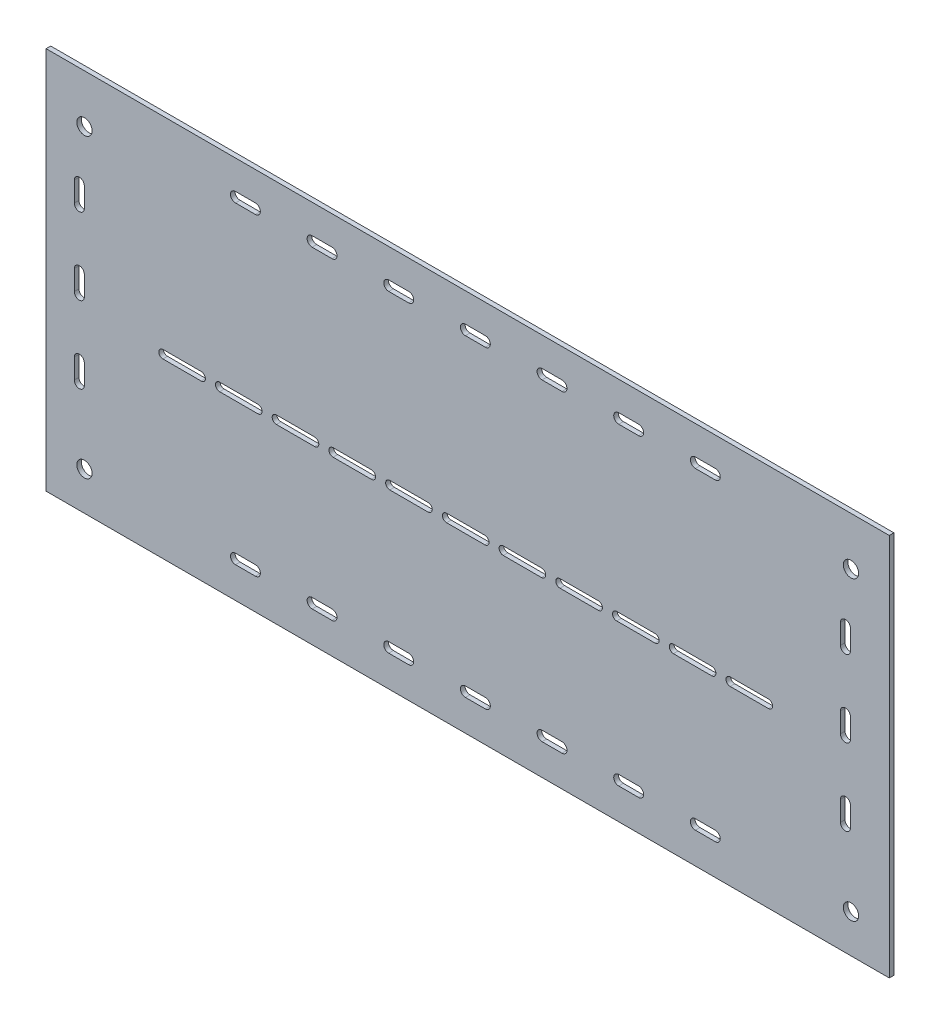
from build123d import *

# Parameters (mm, degrees)
CROQUIS1_W              = 550
CROQUIS1_H              = 250
SALIENTE_EXTRUIR1_DEPTH = 3
CROQUIS2_R              = 5
CORTAR_EXTRUIR1_DEPTH   = 4
CORTAR_EXTRUIR2_DEPTH   = 4


with BuildPart() as part:
    # Croquis1 → Saliente-Extruir1 (new body)
    with BuildSketch(Plane.XY):
        Rectangle(CROQUIS1_W, CROQUIS1_H)
    extrude(amount=SALIENTE_EXTRUIR1_DEPTH)

    # Croquis2 → Cortar-Extruir1 (cut, through all)
    with BuildSketch(Plane(origin=(0, 0, 0), x_dir=(-1, 0, 0), z_dir=(0, 0, -1))):
        with Locations((-250, -100)):
            Circle(CROQUIS2_R)
        with Locations((250, -100)):
            Circle(CROQUIS2_R)
        with Locations((250, 93.5)):
            Circle(CROQUIS2_R)
        with Locations((-250, 93.5)):
            Circle(CROQUIS2_R)
    extrude(amount=-CORTAR_EXTRUIR1_DEPTH, mode=Mode.SUBTRACT)

    # Croquis3 → Cortar-Extruir2 (cut, through all)
    with BuildSketch(Plane.XY.offset(3)):
        with BuildLine():
            Line((171.181949448, -12.194513293), (196.181949448, -12.194513293))
            ThreePointArc((196.181949448, -12.194513293), (198.091137757, -11.403701602), (198.881949448, -9.494513293))
            ThreePointArc((198.881949448, -9.494513293), (198.091137757, -7.585324983), (196.181949448, -6.794513293))
            Line((196.181949448, -6.794513293), (171.181949448, -6.794513293))
            ThreePointArc((171.181949448, -6.794513293), (168.481949448, -9.494513293), (171.181949448, -12.194513293))
        make_face()
        with BuildLine():
            Line((97.181949448, -12.194513293), (122.181949448, -12.194513293))
            ThreePointArc((122.181949448, -12.194513293), (124.091137757, -11.403701602), (124.881949448, -9.494513293))
            ThreePointArc((124.881949448, -9.494513293), (124.091137757, -7.585324983), (122.181949448, -6.794513293))
            Line((122.181949448, -6.794513293), (97.181949448, -6.794513293))
            ThreePointArc((97.181949448, -6.794513293), (94.481949448, -9.494513293), (97.181949448, -12.194513293))
        make_face()
        with BuildLine():
            Line((159.181949448, -6.794513293), (134.181949448, -6.794513293))
            ThreePointArc((134.181949448, -6.794513293), (131.481949448, -9.494513293), (134.181949448, -12.194513293))
            Line((134.181949448, -12.194513293), (159.181949448, -12.194513293))
            ThreePointArc((159.181949448, -12.194513293), (161.091137757, -11.403701602), (161.881949448, -9.494513293))
            ThreePointArc((161.881949448, -9.494513293), (161.091137757, -7.585324983), (159.181949448, -6.794513293))
        make_face()
        with BuildLine():
            Line((23.181949448, -12.194513293), (48.181949448, -12.194513293))
            ThreePointArc((48.181949448, -12.194513293), (50.091137757, -11.403701602), (50.881949448, -9.494513293))
            ThreePointArc((50.881949448, -9.494513293), (50.091137757, -7.585324983), (48.181949448, -6.794513293))
            Line((48.181949448, -6.794513293), (23.181949448, -6.794513293))
            ThreePointArc((23.181949448, -6.794513293), (20.481949448, -9.494513293), (23.181949448, -12.194513293))
        make_face()
        with BuildLine():
            Line((85.181949448, -6.794513293), (60.181949448, -6.794513293))
            ThreePointArc((60.181949448, -6.794513293), (57.481949448, -9.494513293), (60.181949448, -12.194513293))
            Line((60.181949448, -12.194513293), (85.181949448, -12.194513293))
            ThreePointArc((85.181949448, -12.194513293), (87.091137757, -11.403701602), (87.881949448, -9.494513293))
            ThreePointArc((87.881949448, -9.494513293), (87.091137757, -7.585324983), (85.181949448, -6.794513293))
        make_face()
        with BuildLine():
            Line((-101.5, 99.605015398), (-88.5, 99.605015398))
            ThreePointArc((-88.5, 99.605015398), (-86.201902961, 100.556918359), (-85.25, 102.855015398))
            ThreePointArc((-85.25, 102.855015398), (-86.201902961, 105.153112437), (-88.5, 106.105015398))
            Line((-88.5, 106.105015398), (-101.5, 106.105015398))
            ThreePointArc((-101.5, 106.105015398), (-104.75, 102.855015398), (-101.5, 99.605015398))
        make_face()
        with BuildLine():
            Line((-138.5, 106.105015398), (-151.5, 106.105015398))
            ThreePointArc((-151.5, 106.105015398), (-154.75, 102.855015398), (-151.5, 99.605015398))
            Line((-151.5, 99.605015398), (-138.5, 99.605015398))
            ThreePointArc((-138.5, 99.605015398), (-136.201902961, 100.556918359), (-135.25, 102.855015398))
            ThreePointArc((-135.25, 102.855015398), (-136.201902961, 105.153112437), (-138.5, 106.105015398))
        make_face()
        with BuildLine():
            Line((-1.5, 99.605015398), (11.5, 99.605015398))
            ThreePointArc((11.5, 99.605015398), (13.798097039, 100.556918359), (14.75, 102.855015398))
            ThreePointArc((14.75, 102.855015398), (13.798097039, 105.153112437), (11.5, 106.105015398))
            Line((11.5, 106.105015398), (-1.5, 106.105015398))
            ThreePointArc((-1.5, 106.105015398), (-4.75, 102.855015398), (-1.5, 99.605015398))
        make_face()
        with BuildLine():
            Line((-38.5, 106.105015398), (-51.5, 106.105015398))
            ThreePointArc((-51.5, 106.105015398), (-54.75, 102.855015398), (-51.5, 99.605015398))
            Line((-51.5, 99.605015398), (-38.5, 99.605015398))
            ThreePointArc((-38.5, 99.605015398), (-36.201902961, 100.556918359), (-35.25, 102.855015398))
            ThreePointArc((-35.25, 102.855015398), (-36.201902961, 105.153112437), (-38.5, 106.105015398))
        make_face()
        with BuildLine():
            Line((98.5, 99.605015398), (111.5, 99.605015398))
            ThreePointArc((111.5, 99.605015398), (113.798097039, 100.556918359), (114.75, 102.855015398))
            ThreePointArc((114.75, 102.855015398), (113.798097039, 105.153112437), (111.5, 106.105015398))
            Line((111.5, 106.105015398), (98.5, 106.105015398))
            ThreePointArc((98.5, 106.105015398), (95.25, 102.855015398), (98.5, 99.605015398))
        make_face()
        with BuildLine():
            Line((61.5, 106.105015398), (48.5, 106.105015398))
            ThreePointArc((48.5, 106.105015398), (45.25, 102.855015398), (48.5, 99.605015398))
            Line((48.5, 99.605015398), (61.5, 99.605015398))
            ThreePointArc((61.5, 99.605015398), (63.798097039, 100.556918359), (64.75, 102.855015398))
            ThreePointArc((64.75, 102.855015398), (63.798097039, 105.153112437), (61.5, 106.105015398))
        make_face()
        with BuildLine():
            Line((249.649280183, 47), (249.649280183, 60))
            ThreePointArc((249.649280183, 60), (246.399280183, 63.25), (243.149280183, 60))
            Line((243.149280183, 60), (243.149280183, 47))
            ThreePointArc((243.149280183, 47), (246.399280183, 43.75), (249.649280183, 47))
        make_face()
        with BuildLine():
            Line((161.5, 106.105015398), (148.5, 106.105015398))
            ThreePointArc((148.5, 106.105015398), (145.25, 102.855015398), (148.5, 99.605015398))
            Line((148.5, 99.605015398), (161.5, 99.605015398))
            ThreePointArc((161.5, 99.605015398), (163.798097039, 100.556918359), (164.75, 102.855015398))
            ThreePointArc((164.75, 102.855015398), (163.798097039, 105.153112437), (161.5, 106.105015398))
        make_face()
        with BuildLine():
            Line((243.149280183, -40), (243.149280183, -53))
            ThreePointArc((243.149280183, -53), (246.399280183, -56.25), (249.649280183, -53))
            Line((249.649280183, -53), (249.649280183, -40))
            ThreePointArc((249.649280183, -40), (246.399280183, -36.75), (243.149280183, -40))
        make_face()
        with BuildLine():
            Line((243.149280183, 10), (243.149280183, -3))
            ThreePointArc((243.149280183, -3), (246.399280183, -6.25), (249.649280183, -3))
            Line((249.649280183, -3), (249.649280183, 10))
            ThreePointArc((249.649280183, 10), (246.399280183, 13.25), (243.149280183, 10))
        make_face()
        with BuildLine():
            Line((98.5, -104.75), (111.5, -104.75))
            ThreePointArc((111.5, -104.75), (113.798097039, -103.798097039), (114.75, -101.5))
            ThreePointArc((114.75, -101.5), (113.798097039, -99.201902961), (111.5, -98.25))
            Line((111.5, -98.25), (98.5, -98.25))
            ThreePointArc((98.5, -98.25), (95.25, -101.5), (98.5, -104.75))
        make_face()
        with BuildLine():
            Line((161.5, -98.25), (148.5, -98.25))
            ThreePointArc((148.5, -98.25), (145.25, -101.5), (148.5, -104.75))
            Line((148.5, -104.75), (161.5, -104.75))
            ThreePointArc((161.5, -104.75), (163.798097039, -103.798097039), (164.75, -101.5))
            ThreePointArc((164.75, -101.5), (163.798097039, -99.201902961), (161.5, -98.25))
        make_face()
        with BuildLine():
            Line((-1.5, -104.75), (11.5, -104.75))
            ThreePointArc((11.5, -104.75), (13.798097039, -103.798097039), (14.75, -101.5))
            ThreePointArc((14.75, -101.5), (13.798097039, -99.201902961), (11.5, -98.25))
            Line((11.5, -98.25), (-1.5, -98.25))
            ThreePointArc((-1.5, -98.25), (-4.75, -101.5), (-1.5, -104.75))
        make_face()
        with BuildLine():
            Line((61.5, -98.25), (48.5, -98.25))
            ThreePointArc((48.5, -98.25), (45.25, -101.5), (48.5, -104.75))
            Line((48.5, -104.75), (61.5, -104.75))
            ThreePointArc((61.5, -104.75), (63.798097039, -103.798097039), (64.75, -101.5))
            ThreePointArc((64.75, -101.5), (63.798097039, -99.201902961), (61.5, -98.25))
        make_face()
        with BuildLine():
            Line((-50.818050552, -12.194513293), (-25.818050552, -12.194513293))
            ThreePointArc((-25.818050552, -12.194513293), (-23.908862243, -11.403701602), (-23.118050552, -9.494513293))
            ThreePointArc((-23.118050552, -9.494513293), (-23.908862243, -7.585324983), (-25.818050552, -6.794513293))
            Line((-25.818050552, -6.794513293), (-50.818050552, -6.794513293))
            ThreePointArc((-50.818050552, -6.794513293), (-53.518050552, -9.494513293), (-50.818050552, -12.194513293))
        make_face()
        with BuildLine():
            Line((11.181949448, -6.794513293), (-13.818050552, -6.794513293))
            ThreePointArc((-13.818050552, -6.794513293), (-16.518050552, -9.494513293), (-13.818050552, -12.194513293))
            Line((-13.818050552, -12.194513293), (11.181949448, -12.194513293))
            ThreePointArc((11.181949448, -12.194513293), (13.091137757, -11.403701602), (13.881949448, -9.494513293))
            ThreePointArc((13.881949448, -9.494513293), (13.091137757, -7.585324983), (11.181949448, -6.794513293))
        make_face()
        with BuildLine():
            Line((-99.818050552, -6.794513293), (-124.818050552, -6.794513293))
            ThreePointArc((-124.818050552, -6.794513293), (-127.518050552, -9.494513293), (-124.818050552, -12.194513293))
            Line((-124.818050552, -12.194513293), (-99.818050552, -12.194513293))
            ThreePointArc((-99.818050552, -12.194513293), (-97.908862243, -11.403701602), (-97.118050552, -9.494513293))
            ThreePointArc((-97.118050552, -9.494513293), (-97.908862243, -7.585324983), (-99.818050552, -6.794513293))
        make_face()
        with BuildLine():
            Line((-62.818050552, -6.794513293), (-87.818050552, -6.794513293))
            ThreePointArc((-87.818050552, -6.794513293), (-90.518050552, -9.494513293), (-87.818050552, -12.194513293))
            Line((-87.818050552, -12.194513293), (-62.818050552, -12.194513293))
            ThreePointArc((-62.818050552, -12.194513293), (-60.908862243, -11.403701602), (-60.118050552, -9.494513293))
            ThreePointArc((-60.118050552, -9.494513293), (-60.908862243, -7.585324983), (-62.818050552, -6.794513293))
        make_face()
        with BuildLine():
            Line((-173.818050552, -6.794513293), (-198.818050552, -6.794513293))
            ThreePointArc((-198.818050552, -6.794513293), (-201.518050552, -9.494513293), (-198.818050552, -12.194513293))
            Line((-198.818050552, -12.194513293), (-173.818050552, -12.194513293))
            ThreePointArc((-173.818050552, -12.194513293), (-171.908862243, -11.403701602), (-171.118050552, -9.494513293))
            ThreePointArc((-171.118050552, -9.494513293), (-171.908862243, -7.585324983), (-173.818050552, -6.794513293))
        make_face()
        with BuildLine():
            Line((-136.818050552, -6.794513293), (-161.818050552, -6.794513293))
            ThreePointArc((-161.818050552, -6.794513293), (-164.518050552, -9.494513293), (-161.818050552, -12.194513293))
            Line((-161.818050552, -12.194513293), (-136.818050552, -12.194513293))
            ThreePointArc((-136.818050552, -12.194513293), (-134.908862243, -11.403701602), (-134.118050552, -9.494513293))
            ThreePointArc((-134.118050552, -9.494513293), (-134.908862243, -7.585324983), (-136.818050552, -6.794513293))
        make_face()
        with BuildLine():
            Line((-101.5, -104.75), (-88.5, -104.75))
            ThreePointArc((-88.5, -104.75), (-86.201902961, -103.798097039), (-85.25, -101.5))
            ThreePointArc((-85.25, -101.5), (-86.201902961, -99.201902961), (-88.5, -98.25))
            Line((-88.5, -98.25), (-101.5, -98.25))
            ThreePointArc((-101.5, -98.25), (-104.75, -101.5), (-101.5, -104.75))
        make_face()
        with BuildLine():
            Line((-38.5, -98.25), (-51.5, -98.25))
            ThreePointArc((-51.5, -98.25), (-54.75, -101.5), (-51.5, -104.75))
            Line((-51.5, -104.75), (-38.5, -104.75))
            ThreePointArc((-38.5, -104.75), (-36.201902961, -103.798097039), (-35.25, -101.5))
            ThreePointArc((-35.25, -101.5), (-36.201902961, -99.201902961), (-38.5, -98.25))
        make_face()
        with BuildLine():
            Line((-151.5, -104.75), (-138.5, -104.75))
            ThreePointArc((-138.5, -104.75), (-136.201902961, -103.798097039), (-135.25, -101.5))
            ThreePointArc((-135.25, -101.5), (-136.201902961, -99.201902961), (-138.5, -98.25))
            Line((-138.5, -98.25), (-151.5, -98.25))
            ThreePointArc((-151.5, -98.25), (-154.75, -101.5), (-151.5, -104.75))
        make_face()
        with BuildLine():
            Line((-250.09614838, 47), (-250.09614838, 60))
            ThreePointArc((-250.09614838, 60), (-253.34614838, 63.25), (-256.59614838, 60))
            Line((-256.59614838, 60), (-256.59614838, 47))
            ThreePointArc((-256.59614838, 47), (-253.34614838, 43.75), (-250.09614838, 47))
        make_face()
        with BuildLine():
            Line((-256.59614838, 10), (-256.59614838, -3))
            ThreePointArc((-256.59614838, -3), (-253.34614838, -6.25), (-250.09614838, -3))
            Line((-250.09614838, -3), (-250.09614838, 10))
            ThreePointArc((-250.09614838, 10), (-253.34614838, 13.25), (-256.59614838, 10))
        make_face()
        with BuildLine():
            Line((-256.59614838, -40), (-256.59614838, -53))
            ThreePointArc((-256.59614838, -53), (-253.34614838, -56.25), (-250.09614838, -53))
            Line((-250.09614838, -53), (-250.09614838, -40))
            ThreePointArc((-250.09614838, -40), (-253.34614838, -36.75), (-256.59614838, -40))
        make_face()
    extrude(amount=-CORTAR_EXTRUIR2_DEPTH, mode=Mode.SUBTRACT)


solid = part.part
